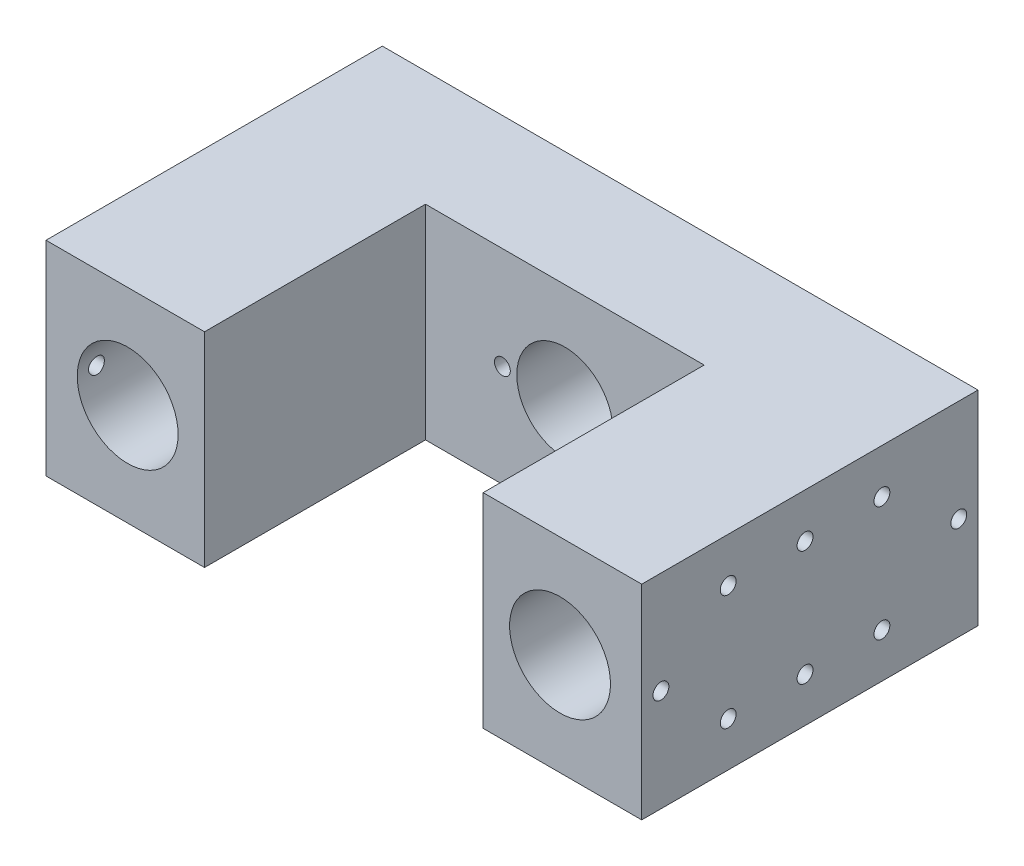
from build123d import *

# Parameters (mm, degrees)
SKETCH1_W           = 124
SKETCH1_H           = 42.5
SKETCH1_R           = 10.5
SKETCH1_R_2         = 10
SKETCH1_R_3         = 1.65
BOSS_EXTRUDE1_DEPTH = 70
SKETCH2_W           = 58
SKETCH2_H           = 42.5
CUT_EXTRUDE1_DEPTH  = 46
SKETCH3_R           = 18.35
CUT_EXTRUDE2_DEPTH  = 5
SKETCH5_R           = 1.65
CUT_EXTRUDE4_DEPTH  = 12
SKETCH6_R           = 1.65
CUT_EXTRUDE5_DEPTH  = 12
CUT_EXTRUDE3_REACH  = 44.5
SKETCH4_R           = 2.1


with BuildPart() as part:
    # Sketch1 → Boss-Extrude1 (new body)
    with BuildSketch(Plane.XY):
        with Locations((62, 21.25)):
            Rectangle(SKETCH1_W, SKETCH1_H)
        with Locations((17, 21.25)):
            Circle(SKETCH1_R, mode=Mode.SUBTRACT)
        with Locations((62, 21.25)):
            Circle(SKETCH1_R_2, mode=Mode.SUBTRACT)
        with Locations((107, 21.25)):
            Circle(SKETCH1_R, mode=Mode.SUBTRACT)
        with Locations((49, 21.25)):
            Circle(SKETCH1_R_3, mode=Mode.SUBTRACT)
        with Locations((75, 21.25)):
            Circle(SKETCH1_R_3, mode=Mode.SUBTRACT)
    extrude(amount=BOSS_EXTRUDE1_DEPTH)

    # Sketch2 → Cut-Extrude1 (cut)
    with BuildSketch(Plane.XY.offset(70)):
        with Locations((62, 21.25)):
            Rectangle(SKETCH2_W, SKETCH2_H)
    extrude(amount=-CUT_EXTRUDE1_DEPTH, mode=Mode.SUBTRACT)

    # Sketch3 → Cut-Extrude2 (cut)
    with BuildSketch(Plane(origin=(0, 0, 0), x_dir=(-1, 0, 0), z_dir=(0, 0, -1))):
        with Locations((-62, 21.25)):
            Circle(SKETCH3_R)
    extrude(amount=-CUT_EXTRUDE2_DEPTH, mode=Mode.SUBTRACT)

    # Sketch5 → Cut-Extrude4 (cut)
    with BuildSketch(Plane(origin=(124, 0, 0), x_dir=(0, 0, -1), z_dir=(1, 0, 0))):
        with Locations((-20, 9.25)):
            Circle(SKETCH5_R)
        with Locations((-20, 33.25)):
            Circle(SKETCH5_R)
        with Locations((-36, 33.25)):
            Circle(SKETCH5_R)
        with Locations((-36, 9.25)):
            Circle(SKETCH5_R)
        with Locations((-52, 9.25)):
            Circle(SKETCH5_R)
        with Locations((-52, 33.25)):
            Circle(SKETCH5_R)
        with Locations((-66, 21.25)):
            Circle(SKETCH5_R)
        with Locations((-4, 21.25)):
            Circle(SKETCH5_R)
    extrude(amount=-CUT_EXTRUDE4_DEPTH, mode=Mode.SUBTRACT)

    # Sketch6 → Cut-Extrude5 (cut)
    with BuildSketch(Plane.ZY):
        with Locations((20, 33.25)):
            Circle(SKETCH6_R)
        with Locations((36, 33.25)):
            Circle(SKETCH6_R)
        with Locations((36, 9.25)):
            Circle(SKETCH6_R)
        with Locations((20, 9.25)):
            Circle(SKETCH6_R)
        with Locations((52, 33.25)):
            Circle(SKETCH6_R)
        with Locations((52, 9.25)):
            Circle(SKETCH6_R)
        with Locations((66, 21.25)):
            Circle(SKETCH6_R)
        with Locations((4, 21.25)):
            Circle(SKETCH6_R)
    extrude(amount=-CUT_EXTRUDE5_DEPTH, mode=Mode.SUBTRACT)

    # Sketch4 → Cut-Extrude3 (cut, up to next)
    with BuildSketch(Plane.XZ, mode=Mode.PRIVATE) as cut_extrude3_sk1:
        with Locations((17, 55)):
            Circle(SKETCH4_R)
    cut_extrude3_tool1 = extrude(cut_extrude3_sk1.sketch, amount=-CUT_EXTRUDE3_REACH, mode=Mode.PRIVATE) & part.part
    add(cut_extrude3_tool1.solids().sort_by_distance((17, 0, 55))[0], mode=Mode.SUBTRACT)
    # Sketch4 → Cut-Extrude3 (cut, up to next)
    with BuildSketch(Plane.XZ, mode=Mode.PRIVATE) as cut_extrude3_sk2:
        with Locations((17, 15)):
            Circle(SKETCH4_R)
    cut_extrude3_tool2 = extrude(cut_extrude3_sk2.sketch, amount=-CUT_EXTRUDE3_REACH, mode=Mode.PRIVATE) & part.part
    add(cut_extrude3_tool2.solids().sort_by_distance((17, 0, 15))[0], mode=Mode.SUBTRACT)
    # Sketch4 → Cut-Extrude3 (cut, up to next)
    with BuildSketch(Plane.XZ, mode=Mode.PRIVATE) as cut_extrude3_sk3:
        with Locations((107, 15)):
            Circle(SKETCH4_R)
    cut_extrude3_tool3 = extrude(cut_extrude3_sk3.sketch, amount=-CUT_EXTRUDE3_REACH, mode=Mode.PRIVATE) & part.part
    add(cut_extrude3_tool3.solids().sort_by_distance((107, 0, 15))[0], mode=Mode.SUBTRACT)
    # Sketch4 → Cut-Extrude3 (cut, up to next)
    with BuildSketch(Plane.XZ, mode=Mode.PRIVATE) as cut_extrude3_sk4:
        with Locations((107, 55)):
            Circle(SKETCH4_R)
    cut_extrude3_tool4 = extrude(cut_extrude3_sk4.sketch, amount=-CUT_EXTRUDE3_REACH, mode=Mode.PRIVATE) & part.part
    add(cut_extrude3_tool4.solids().sort_by_distance((107, 0, 55))[0], mode=Mode.SUBTRACT)


solid = part.part
